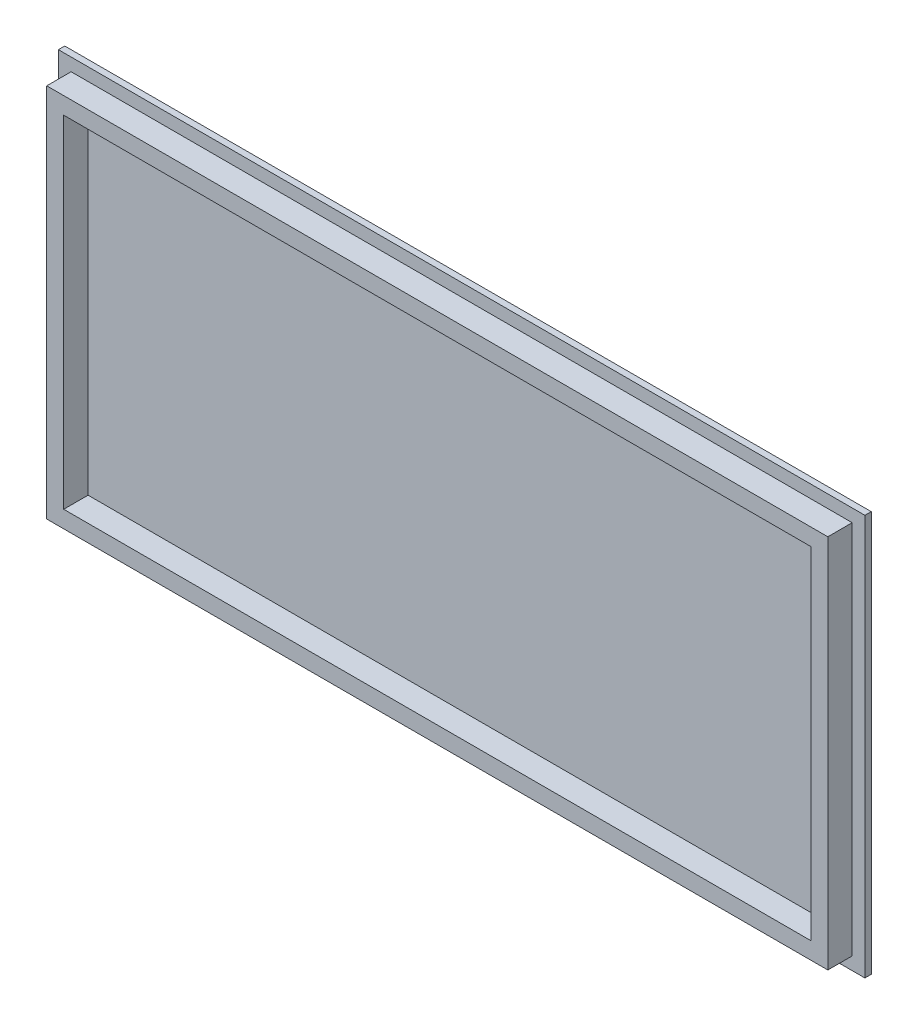
from build123d import *

# Parameters (mm, degrees)
SKETCH_2_W          = 380.47
SKETCH_2_H          = 189.04
EXTRUDE_1_DEPTH     = 3
SKETCH_3_W          = 368.48
SKETCH_3_H          = 177.01
EXTRUDE_2_DEPTH     = 11.5
SKETCH_4_W          = 352.48
SKETCH_4_H          = 161.01
CUT_EXTRUDE_1_DEPTH = 11.5


with BuildPart() as part:
    # 草图2 → 凸台-拉伸1 (new body)
    with BuildSketch(Plane.XY):
        with Locations((183.815306963, 88.27515573)):
            Rectangle(SKETCH_2_W, SKETCH_2_H)
    extrude(amount=EXTRUDE_1_DEPTH)

    # 草图3 → 凸台-拉伸2 (add)
    with BuildSketch(Plane.XY.offset(3)):
        with Locations((183.815306963, 88.27515573)):
            Rectangle(SKETCH_3_W, SKETCH_3_H)
    extrude(amount=EXTRUDE_2_DEPTH)

    # 草图4 → 切除-拉伸1 (cut)
    with BuildSketch(Plane.XY.offset(14.5)):
        with Locations((183.815306963, 88.27515573)):
            Rectangle(SKETCH_4_W, SKETCH_4_H)
    extrude(amount=-CUT_EXTRUDE_1_DEPTH, mode=Mode.SUBTRACT)


solid = part.part
